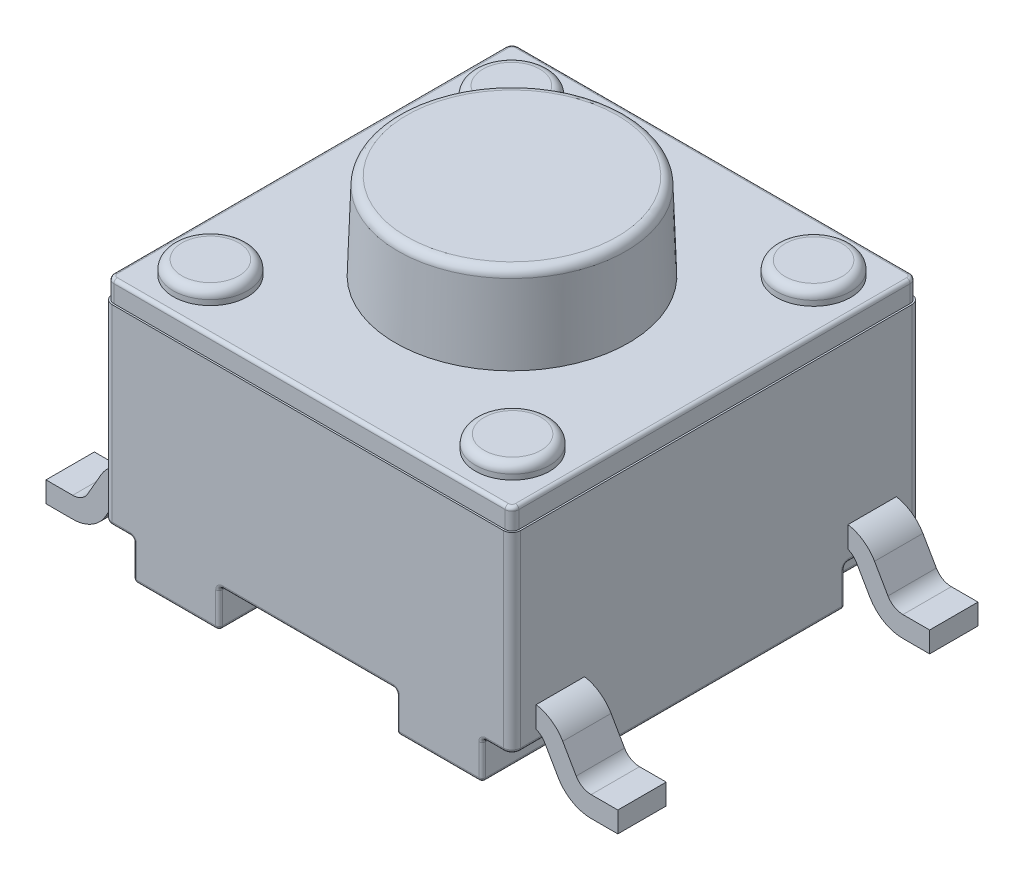
from build123d import *

# Parameters (mm, degrees)
BOSS_EXTRUDE1_START  = 0.5588
SKETCH1_W            = 6.0071
SKETCH1_H            = 6.0071
BOSS_EXTRUDE1_DEPTH  = 2.8194
FILLET1_R            = 0.127
BOSS_EXTRUDE2_DEPTH  = 0.3048
BOSS_EXTRUDE3_REACH  = 5.683
SKETCH4_R            = 0.5461
BOSS_EXTRUDE4_DEPTH  = 0.2032
SKETCH5_R            = 1.7145
BOSS_EXTRUDE5_DEPTH  = 1.27
BOSS_EXTRUDE5_TAPER  = 2
FILLET2_R            = 0.127
FILLET3_R            = 0.0508
EXTRUDE_THIN1_START  = -0.3556
EXTRUDE_THIN1_DEPTH  = 0.7112
MIRROR3_START        = -0.3556
MIRROR3_COPY_1_DEPTH = 0.7112


with BuildPart() as part:
    # Sketch1 → Boss-Extrude1 (new body)
    with BuildSketch(Plane(origin=(0, 0, 0), x_dir=(1, 0, 0), z_dir=(0, 1, 0)).offset(BOSS_EXTRUDE1_START)):
        Rectangle(SKETCH1_W, SKETCH1_H)
    extrude(amount=BOSS_EXTRUDE1_DEPTH)

    # Fillet1
    fillet1_edges = [part.edges().sort_by_distance(p)[0] for p in [
        (3.00355, 1.9685, 3.00355),
        (-3.00355, 1.9685, 3.00355),
        (-3.00355, 1.9685, -3.00355),
        (3.00355, 1.9685, -3.00355),
    ]]
    fillet(fillet1_edges, radius=FILLET1_R)

    # Sketch2 → Boss-Extrude2 (add)
    with BuildSketch(Plane(origin=(0, 3.3782, 0), x_dir=(-1, 0, 0), z_dir=(0, -1, 0))):
        with BuildLine():
            Line((2.97815, -2.87655), (2.97815, 2.87655))
            ThreePointArc((2.97815, 2.87655), (2.948392049, 2.948392049), (2.87655, 2.97815))
            Line((2.87655, 2.97815), (-2.87655, 2.97815))
            ThreePointArc((-2.87655, 2.97815), (-2.948392049, 2.948392049), (-2.97815, 2.87655))
            Line((-2.97815, 2.87655), (-2.97815, -2.87655))
            ThreePointArc((-2.97815, -2.87655), (-2.948392049, -2.948392049), (-2.87655, -2.97815))
            Line((-2.87655, -2.97815), (2.87655, -2.97815))
            ThreePointArc((2.87655, -2.97815), (2.948392049, -2.948392049), (2.97815, -2.87655))
        make_face()
    extrude(amount=-BOSS_EXTRUDE2_DEPTH)

    # Sketch3 → Boss-Extrude3 (add, up to next)
    with BuildSketch(Plane(origin=(0, 0, 0), x_dir=(1, 0, 0), z_dir=(0, 1, 0)), mode=Mode.PRIVATE) as boss_extrude3_sk1:
        Polygon((-2.566197678, -3.00355), (-2.566197678, -1.89483443), (-3.00355, -1.89483443), (-3.00355, 1.89483443), (-2.566197678, 1.89483443), (-2.566197678, 3.00355), (-1.30175, 3.00355), (-1.30175, 0.560941661), (-2.441300776, 0.560941661), (-2.441300776, -0.560941661), (-1.30175, -0.560941661), (-1.30175, -3.00355), align=None)
    boss_extrude3_tool1 = extrude(boss_extrude3_sk1.sketch, amount=BOSS_EXTRUDE3_REACH, mode=Mode.PRIVATE) - part.part
    add(boss_extrude3_tool1.solids().sort_by_distance((-2.503763, 0, 2.449192))[0])
    # Sketch3 → Boss-Extrude3 (add, up to next)
    with BuildSketch(Plane(origin=(0, 0, 0), x_dir=(1, 0, 0), z_dir=(0, 1, 0)), mode=Mode.PRIVATE) as boss_extrude3_sk2:
        Polygon((2.566197678, 3.00355), (2.566197678, 1.89483443), (3.00355, 1.89483443), (3.00355, -1.89483443), (2.566197678, -1.89483443), (2.566197678, -3.00355), (1.30175, -3.00355), (1.30175, -0.560941661), (2.441300776, -0.560941661), (2.441300776, 0.560941661), (1.30175, 0.560941661), (1.30175, 3.00355), align=None)
    boss_extrude3_tool2 = extrude(boss_extrude3_sk2.sketch, amount=BOSS_EXTRUDE3_REACH, mode=Mode.PRIVATE) - part.part
    add(boss_extrude3_tool2.solids().sort_by_distance((2.503763, 0, -2.449192))[0])

    # Sketch4 → Boss-Extrude4 (add)
    with BuildSketch(Plane(origin=(0, 3.683, 0), x_dir=(1, 0, 0), z_dir=(0, 1, 0))):
        with Locations(Location((2.221694311, 2.212885437, 0), (0, 0, 90))):  # turned: the seam where the file's is
            Circle(SKETCH4_R)
        with Locations(Location((-2.221694311, 2.212885437, 0), (0, 0, 90))):  # turned: the seam where the file's is
            Circle(SKETCH4_R)
        with Locations(Location((-2.221694311, -2.212885437, 0), (0, 0, 90))):  # turned: the seam where the file's is
            Circle(SKETCH4_R)
        with Locations(Location((2.221694311, -2.212885437, 0), (0, 0, 90))):  # turned: the seam where the file's is
            Circle(SKETCH4_R)
    extrude(amount=BOSS_EXTRUDE4_DEPTH)

    # Sketch5 → Boss-Extrude5 (add)
    with BuildSketch(Plane(origin=(0, 3.683, 0), x_dir=(1, 0, 0), z_dir=(0, 1, 0))):
        Circle(SKETCH5_R)
    extrude(amount=BOSS_EXTRUDE5_DEPTH, taper=BOSS_EXTRUDE5_TAPER)

    # Fillet2
    fillet2_edges = [part.edges().sort_by_distance(p)[0] for p in [
        (2.221694311, 3.8862, -1.666785437),
        (-2.221694311, 3.8862, -1.666785437),
        (-2.221694311, 3.8862, 2.758985437),
        (2.221694311, 3.8862, 2.758985437),
        (-1.670150623, 4.953, 0),
    ]]
    fillet(fillet2_edges, radius=FILLET2_R)

    # Fillet3
    fillet3_edges = [part.edges().sort_by_distance(p)[0] for p in [
        (1.30175, 0.5588, -1.782245831),
        (1.30175, 0.2794, -3.00355),
        (1.30175, 0, -1.782245831),
        (1.871525388, 0.5588, -0.560941661),
        (1.30175, 0.2794, -0.560941661),
        (1.871525388, 0, -0.560941661),
        (2.441300776, 0.5588, 0),
        (2.441300776, 0.2794, -0.560941661),
        (2.441300776, 0, 0),
        (1.871525388, 0.5588, 0.560941661),
        (2.441300776, 0.2794, 0.560941661),
        (1.871525388, 0, 0.560941661),
        (1.30175, 0.5588, 1.782245831),
        (1.30175, 0.2794, 0.560941661),
        (1.30175, 0, 1.782245831),
        (1.30175, 0.2794, 3.00355),
        (1.933973839, 0, 3.00355),
        (2.566197678, 0.5588, 2.449192215),
        (2.566197678, 0.2794, 3.00355),
        (2.566197678, 0, 2.449192215),
        (2.784873839, 0.5588, 1.89483443),
        (2.566197678, 0.2794, 1.89483443),
        (2.784873839, 0, 1.89483443),
        (3.00355, 0.2794, 1.89483443),
        (3.00355, 0, 0),
        (2.784873839, 0.5588, -1.89483443),
        (3.00355, 0.2794, -1.89483443),
        (2.784873839, 0, -1.89483443),
        (2.566197678, 0.2794, -3.00355),
        (1.933973839, 0, -3.00355),
        (2.566197678, 0.5588, -2.449192215),
        (2.566197678, 0.2794, -1.89483443),
        (2.566197678, 0, -2.449192215),
        (-2.721373839, 0.5588, 3.00355),
        (3.00355, 0.5588, 2.385692215),
        (-3.00355, 0.5588, -2.385692215),
        (2.721373839, 0.5588, -3.00355),
        (2.966352561, 0.5588, 2.966352561),
        (2.966352561, 0.5588, -2.966352561),
        (-2.966352561, 0.5588, -2.966352561),
        (-2.966352561, 0.5588, 2.966352561),
        (-2.948392049, 3.683, 2.948392049),
        (0, 3.683, 2.97815),
        (2.948392049, 3.683, 2.948392049),
        (2.97815, 3.683, 0),
        (2.948392049, 3.683, -2.948392049),
        (0, 3.683, -2.97815),
        (-2.948392049, 3.683, -2.948392049),
        (-2.97815, 3.683, 0),
        (0, 0.5588, 3.00355),
        (-3.00355, 0.5588, 2.385692215),
        (-2.721373839, 0.5588, -3.00355),
        (-1.30175, 0.5588, 1.782245831),
        (-1.30175, 0.2794, 3.00355),
        (-1.30175, 0, 1.782245831),
        (-1.871525388, 0.5588, 0.560941661),
        (-1.30175, 0.2794, 0.560941661),
        (-1.871525388, 0, 0.560941661),
        (-2.441300776, 0.5588, 0),
        (-2.441300776, 0.2794, 0.560941661),
        (-2.441300776, 0, 0),
        (-1.871525388, 0.5588, -0.560941661),
        (-2.441300776, 0.2794, -0.560941661),
        (-1.871525388, 0, -0.560941661),
        (-1.30175, 0.5588, -1.782245831),
        (-1.30175, 0.2794, -0.560941661),
        (-1.30175, 0, -1.782245831),
        (-1.30175, 0.2794, -3.00355),
        (-1.933973839, 0, -3.00355),
        (-2.566197678, 0.5588, -2.449192215),
        (-2.566197678, 0.2794, -3.00355),
        (-2.566197678, 0, -2.449192215),
        (-2.784873839, 0.5588, -1.89483443),
        (-2.566197678, 0.2794, -1.89483443),
        (-2.784873839, 0, -1.89483443),
        (-3.00355, 0.2794, -1.89483443),
        (-3.00355, 0, 0),
        (-2.784873839, 0.5588, 1.89483443),
        (-3.00355, 0.2794, 1.89483443),
        (-2.784873839, 0, 1.89483443),
        (-2.566197678, 0.2794, 3.00355),
        (-1.933973839, 0, 3.00355),
        (-2.566197678, 0.5588, 2.449192215),
        (-2.566197678, 0.2794, 1.89483443),
        (-2.566197678, 0, 2.449192215),
        (0, 0.5588, -3.00355),
        (3.00355, 0.5588, -2.385692215),
        (2.721373839, 0.5588, 3.00355),
    ]]
    fillet(fillet3_edges, radius=FILLET3_R)

    # Sketch6 → Extrude-Thin1 (add)
    with BuildSketch(Plane.XY.offset(3.00355).offset(EXTRUDE_THIN1_START)):
        with BuildLine():
            Line((-2.526489479, 0.749452361), (-2.910026465, 0.749452361))
            ThreePointArc((-2.910026465, 0.749452361), (-3.037103393, 0.715378382), (-3.130085701, 0.622298459))
            Line((-3.130085701, 0.622298459), (-3.327543368, 0.279738585))
            ThreePointArc((-3.327543368, 0.279738585), (-3.532104447, 0.074962755), (-3.811673688, 0))
            Line((-3.811673688, 0), (-4.204053366, 0))
            Line((-4.204053366, 0), (-4.204053366, 0.3048))
            Line((-4.204053366, 0.3048), (-3.811673688, 0.3048))
            ThreePointArc((-3.811673688, 0.3048), (-3.68459676, 0.33887398), (-3.591614452, 0.431953902))
            Line((-3.591614452, 0.431953902), (-3.394156785, 0.774513777))
            ThreePointArc((-3.394156785, 0.774513777), (-3.189595706, 0.979289606), (-2.910026465, 1.054252361))
            Line((-2.910026465, 1.054252361), (-2.526489479, 1.054252361))
            Line((-2.526489479, 1.054252361), (-2.526489479, 0.749452361))
        make_face()
    extrude_thin1 = extrude(amount=-EXTRUDE_THIN1_DEPTH)

    # Mirror1: Extrude-Thin1 across plane
    add(extrude_thin1.mirror(Plane.XY))

    # Mirror3: Extrude-Thin1 across plane
    add(extrude_thin1.mirror(Plane(origin=(0, 0, 0), x_dir=(0, 0, 1), z_dir=(1, 0, 0))))

    # Mirror3 copy 1 sketch → Mirror3 copy 1 (add)
    with BuildSketch(Plane(origin=(0, 0, -3.00355), x_dir=(-1, 0, 0), z_dir=(0, 0, -1)).offset(MIRROR3_START)):
        with BuildLine():
            Line((-2.526489479, 0.749452361), (-2.910026465, 0.749452361))
            ThreePointArc((-2.910026465, 0.749452361), (-3.037103393, 0.715378382), (-3.130085701, 0.622298459))
            Line((-3.130085701, 0.622298459), (-3.327543368, 0.279738585))
            ThreePointArc((-3.327543368, 0.279738585), (-3.532104447, 0.074962755), (-3.811673688, 0))
            Line((-3.811673688, 0), (-4.204053366, 0))
            Line((-4.204053366, 0), (-4.204053366, 0.3048))
            Line((-4.204053366, 0.3048), (-3.811673688, 0.3048))
            ThreePointArc((-3.811673688, 0.3048), (-3.68459676, 0.33887398), (-3.591614452, 0.431953902))
            Line((-3.591614452, 0.431953902), (-3.394156785, 0.774513777))
            ThreePointArc((-3.394156785, 0.774513777), (-3.189595706, 0.979289606), (-2.910026465, 1.054252361))
            Line((-2.910026465, 1.054252361), (-2.526489479, 1.054252361))
            Line((-2.526489479, 1.054252361), (-2.526489479, 0.749452361))
        make_face()
    extrude(amount=-MIRROR3_COPY_1_DEPTH)


solid = part.part
